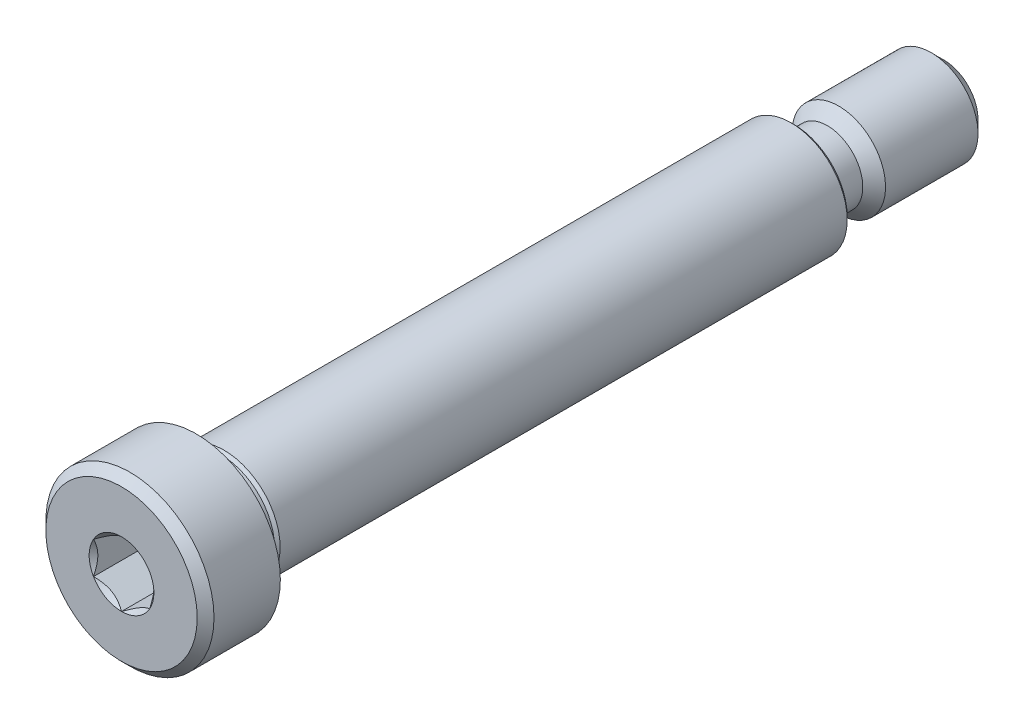
from build123d import *

# Parameters (mm, degrees)
CUT_EXTRUDE1_DEPTH = 4.7625


with BuildPart() as part:
    # Sketch4 → Revolve1 (revolve)
    with BuildSketch(Plane(origin=(0, 0, 0), x_dir=(0, 0, -1), z_dir=(1, 0, 0))):
        Polygon((-28.575, 7.14375), (-34.210625, 7.14375), (-34.925, 6.429375), (-34.925, 0), (22.225, 0), (22.225, 4.500033333), (21.962533333, 4.7625), (-26.2128, 4.7625), (-26.450925, 4.524375), (-28.336875, 4.524375), (-28.575, 4.7625), align=None)
    revolve(axis=Axis((0, 0, 34.925), (0, 0, -1)))

    # Sketch5 → Cut-Extrude1 (cut)
    with BuildSketch(Plane.XY.offset(34.925)):
        Polygon((2.38125, 1.374815329), (0, 2.749630657), (-2.38125, 1.374815329), (-2.38125, -1.374815329), (0, -2.749630657), (2.38125, -1.374815329), align=None)
    extrude(amount=-CUT_EXTRUDE1_DEPTH, mode=Mode.SUBTRACT)

    # Cut-Extrude4 cone 1 section (through the dimple's axis) → Cut-Extrude4 (revolve, cut)
    with BuildSketch(Plane(origin=(0, 0, 34.925), x_dir=(0, -1, 0), z_dir=(1, 0, 0))):
        Polygon((0, 0), (2.749630657, 0), (0, 2.749630657), align=None)
    revolve(axis=Axis((0, 0, 34.925), (0, 0, -1)), mode=Mode.SUBTRACT)

    # Sketch7 → Revolve2 (revolve)
    with BuildSketch(Plane(origin=(0, 0, 0), x_dir=(0, 0, -1), z_dir=(1, 0, 0))):
        Polygon((22.225, 3.9751), (33.866666667, 3.9751), (34.925, 2.916766667), (34.925, 0), (22.225, 0), align=None)
    revolve(axis=Axis((0, 0, -34.925), (0, 0, 1)))

    # Sketch10 → Cut-Revolve1 (revolve, cut)
    with BuildSketch(Plane(origin=(0, 0, 0), x_dir=(0, 0, -1), z_dir=(1, 0, 0))):
        with BuildLine():
            Line((23.1902, 3.0099), (25.0444, 3.0099))
            Line((25.0444, 3.0099), (26.797, 4.7625))
            Line((26.797, 4.7625), (22.225, 4.7625))
            Line((22.225, 4.7625), (22.225, 3.9751))
            ThreePointArc((22.225, 3.9751), (22.507700535, 3.292600535), (23.1902, 3.0099))
        make_face()
    revolve(axis=Axis((0, 0, -34.925), (0, 0, 1)), mode=Mode.SUBTRACT)


solid = part.part
